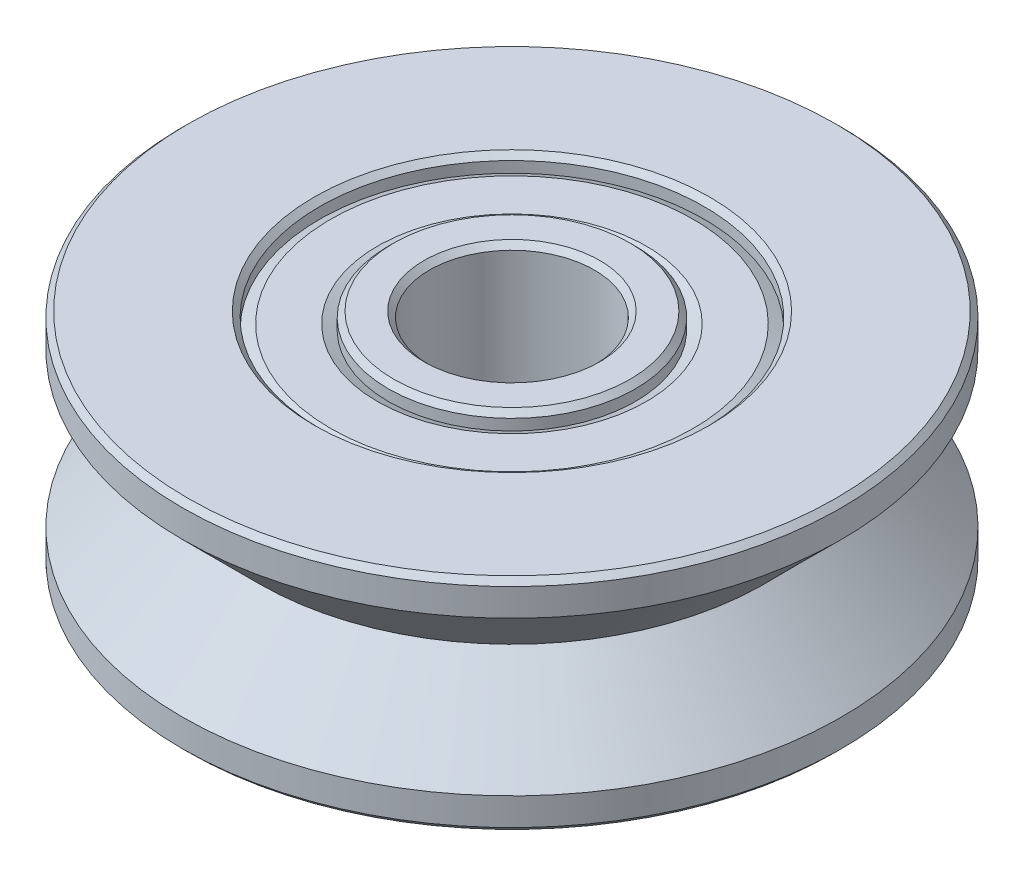
from build123d import *

# Parameters (mm, degrees)
CHAMFER1_SIZE = 0.1


with BuildPart() as part:
    # Sketch1 → Revolve1 (revolve)
    with BuildSketch(Plane(origin=(0, 0, 0), x_dir=(0, 0, -1), z_dir=(1, 0, 0))):
        Polygon((4.6, 0), (6, 1.4), (6, 2), (1.5, 2), (1.5, -2), (6, -2), (6, -1.4), align=None)
    revolve(axis=Axis((0, 2, 0), (0, -1, 0)))

    # Sketch3 → Cut-Revolve2 (revolve, cut)
    with BuildSketch(Plane(origin=(0, 0, 0), x_dir=(0, 0, -1), z_dir=(1, 0, 0))):
        Polygon((3.3, 1.8), (3.5, 1.7), (3.5, 2), (2.25, 2), (2.25, 1.7), (2.45, 1.8), align=None)
    cut_revolve2 = revolve(axis=Axis((0, 2, 0), (0, -1, 0)), mode=Mode.SUBTRACT)

    # Mirror1: Cut-Revolve2 across plane
    add(cut_revolve2.mirror(Plane.ZX), mode=Mode.SUBTRACT)

    # Chamfer1
    chamfer1_edges = [part.edges().sort_by_distance(p)[0] for p in [
        (0, 2, 3.5),
        (0, 2, 2.25),
        (0, -2, 3.5),
        (0, -2, 2.25),
        (0, 2, 6),
        (0, -2, 6),
        (0, -2, 1.5),
        (0, 2, 1.5),
    ]]
    chamfer(chamfer1_edges, length=CHAMFER1_SIZE)


solid = part.part
